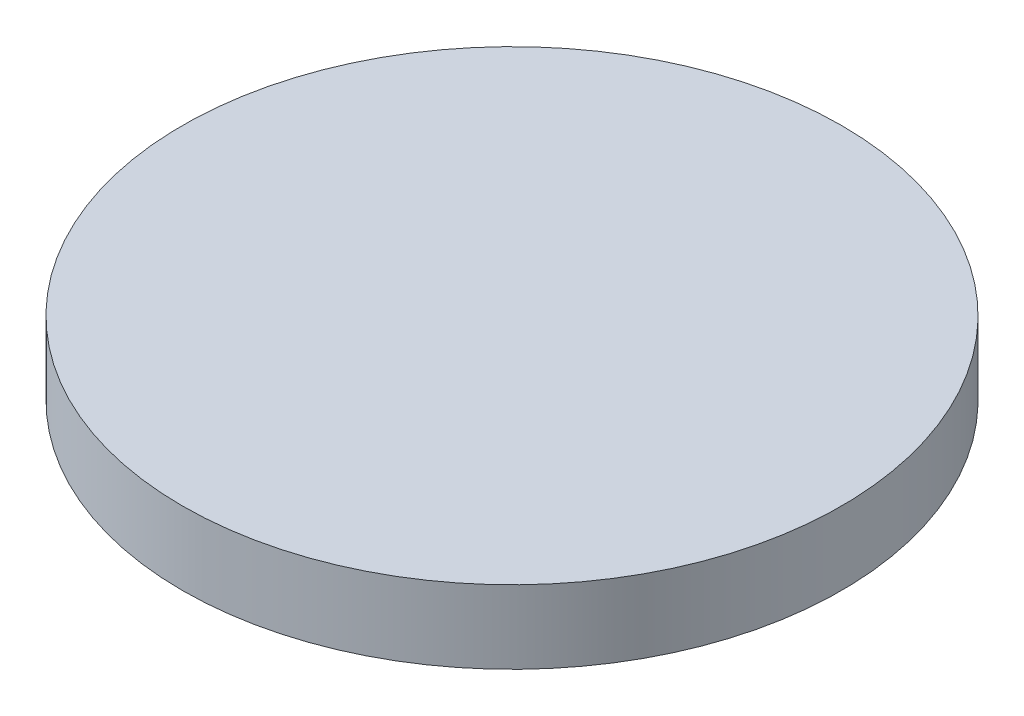
from build123d import *

# Parameters (mm, degrees)
SKETCH2_R           = 45
BOSS_EXTRUDE1_DEPTH = 10


with BuildPart() as part:
    # Sketch2 → Boss-Extrude1 (new body)
    with BuildSketch(Plane(origin=(0, 0, 0), x_dir=(1, 0, 0), z_dir=(0, 1, 0))):
        Circle(SKETCH2_R)
    extrude(amount=BOSS_EXTRUDE1_DEPTH)


solid = part.part
